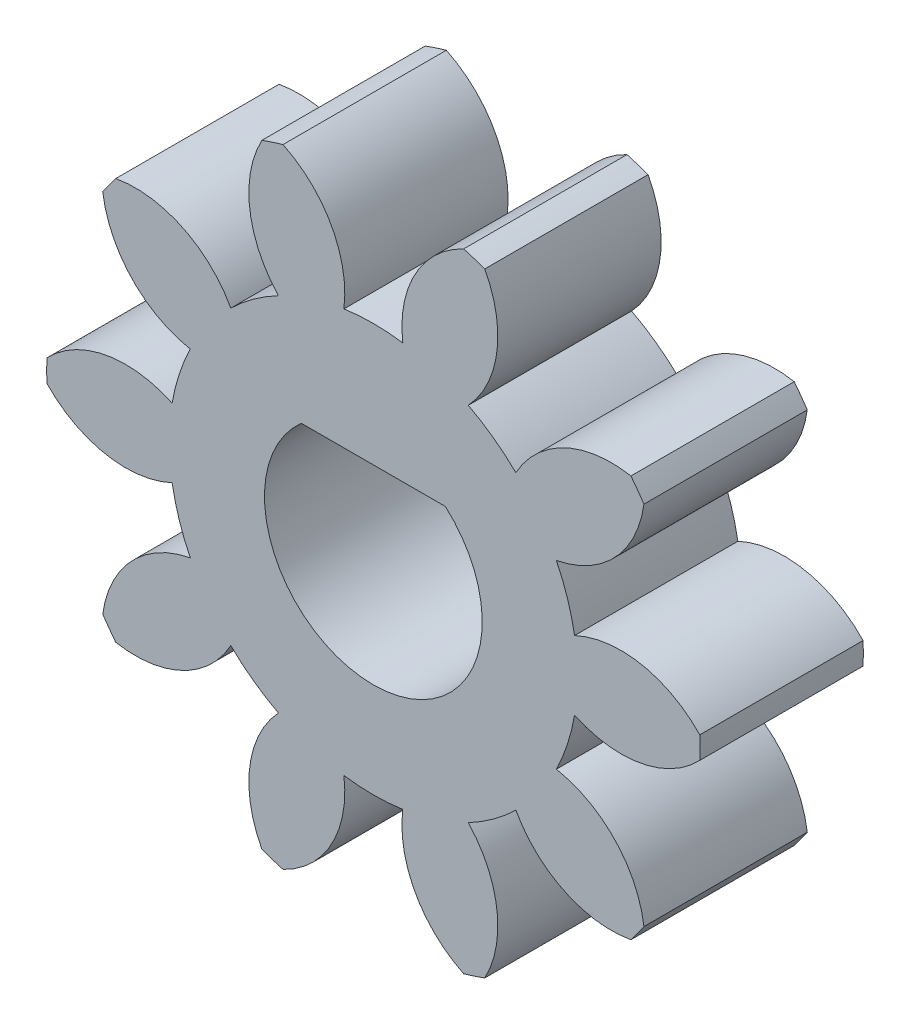
from build123d import *

# Parameters (mm, degrees)
SKETCH1_R           = 6
BOSS_EXTRUDE1_DEPTH = 3
CUT_EXTRUDE2_DEPTH  = 4
CIRPATTERN1_COUNT   = 10
CUT_EXTRUDE4_DEPTH  = 4


with BuildPart() as part:
    # Sketch1 → Boss-Extrude1 (new body)
    with BuildSketch(Plane.XY):
        Circle(SKETCH1_R)
    extrude(amount=BOSS_EXTRUDE1_DEPTH)

    # Sketch2 → Cut-Extrude2 (cut, through all)
    with BuildSketch(Plane(origin=(0, 0, 0), x_dir=(-1, 0, 0), z_dir=(0, 0, -1))):
        with BuildLine():
            ThreePointArc((-1.659502931, 5.765938781), (-0.768019042, 4.919153149), (-0.540379921, 3.710861024))
            ThreePointArc((-0.540379921, 3.710861024), (0, 3.75), (0.540379921, 3.710861024))
            ThreePointArc((0.540379921, 3.710861024), (0.768019042, 4.919153149), (1.659502931, 5.765938781))
            ThreePointArc((1.659502931, 5.765938781), (0, 6), (-1.659502931, 5.765938781))
        make_face()
    cut_extrude2 = extrude(amount=-CUT_EXTRUDE2_DEPTH, mode=Mode.SUBTRACT)

    # CirPattern1: Cut-Extrude2 ×10 about axis
    cirpattern1_axis = Axis((0, 0, 0), (0, 0, 1))
    for i in range(1, CIRPATTERN1_COUNT):
        add(cut_extrude2.rotate(cirpattern1_axis, i * 360 / CIRPATTERN1_COUNT), mode=Mode.SUBTRACT)

    # Sketch4 → Cut-Extrude4 (cut, through all)
    with BuildSketch(Plane(origin=(0, 0, 0), x_dir=(-1, 0, 0), z_dir=(0, 0, -1))):
        with BuildLine():
            Line((-1.322875656, 1.5), (1.322875656, 1.5))
            ThreePointArc((1.322875656, 1.5), (0, -2), (-1.322875656, 1.5))
        make_face()
    extrude(amount=-CUT_EXTRUDE4_DEPTH, mode=Mode.SUBTRACT)


solid = part.part
